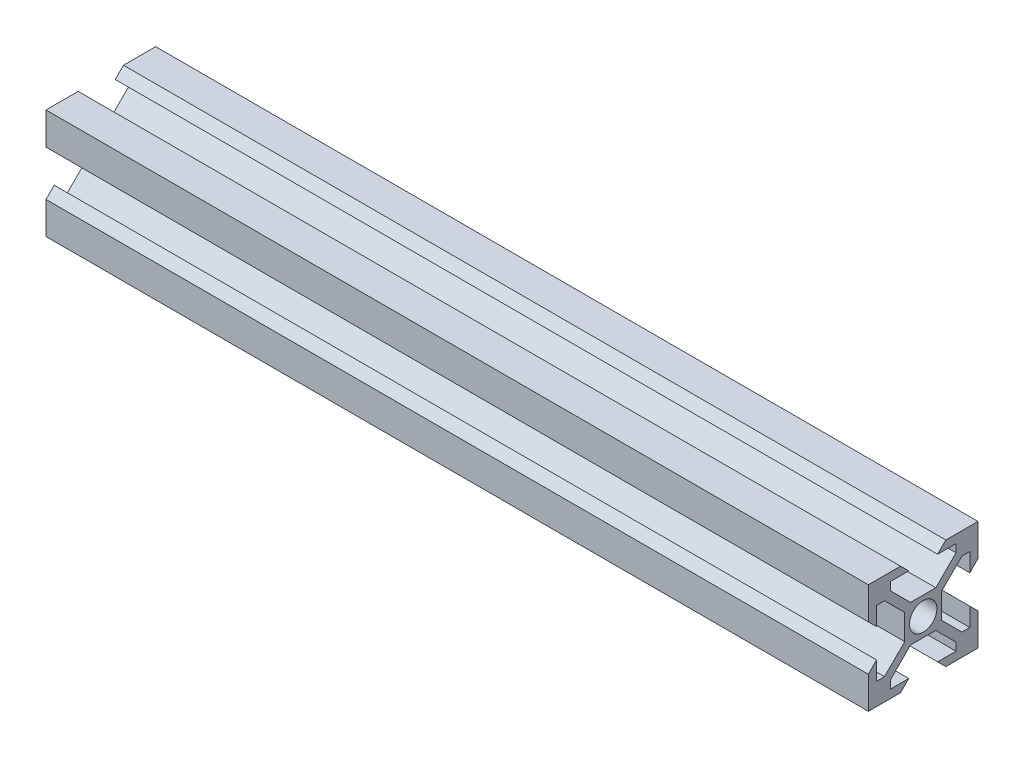
from build123d import *

# Parameters (mm, degrees)
BOSS_EXTRUDE1_DEPTH = 150


with BuildPart() as part:
    # Sketch1 → Boss-Extrude1 (new body)
    with BuildSketch(Plane(origin=(0, 0, 0), x_dir=(0, 0, -1), z_dir=(1, 0, 0))):
        Polygon((8.939339828, -10), (5.995, -7.055660172), (5.995, -8.5), (2.63, -8.5), (4.13, -10), align=None)
        Polygon((8.5, -5.995), (7.055660172, -5.995), (10, -8.939339828), (10, -4.13), (8.5, -2.63), align=None)
        Polygon((7.055660172, -5.995), (3.365, -2.304339828), (3.365, -3.365), (2.304339828, -3.365), (5.995, -7.055660172), (8.939339828, -10), (10, -10), (10, -8.939339828), align=None)
        with BuildLine():
            Line((3.365, -3.365), (3.365, -2.304339828))
            Line((3.365, -2.304339828), (2.216672281, -1.15601211))
            ThreePointArc((2.216672281, -1.15601211), (1.767766953, -1.767766953), (1.15601211, -2.216672281))
            Line((1.15601211, -2.216672281), (2.304339828, -3.365))
            Line((2.304339828, -3.365), (3.365, -3.365))
        make_face()
        with BuildLine():
            Line((3.365, -2.304339828), (3.365, 2.304339828))
            Line((3.365, 2.304339828), (2.216672281, 1.15601211))
            ThreePointArc((2.216672281, 1.15601211), (2.428135159, 0.595113139), (2.5, 0))
            ThreePointArc((2.5, 0), (2.428135159, -0.595113139), (2.216672281, -1.15601211))
            Line((2.216672281, -1.15601211), (3.365, -2.304339828))
        make_face()
        with BuildLine():
            Line((2.216672281, 1.15601211), (3.365, 2.304339828))
            Line((3.365, 2.304339828), (3.365, 3.365))
            Line((3.365, 3.365), (2.304339828, 3.365))
            Line((2.304339828, 3.365), (1.15601211, 2.216672281))
            ThreePointArc((1.15601211, 2.216672281), (1.767766953, 1.767766953), (2.216672281, 1.15601211))
        make_face()
        with BuildLine():
            ThreePointArc((-1.15601211, 2.216672281), (0, 2.5), (1.15601211, 2.216672281))
            Line((1.15601211, 2.216672281), (2.304339828, 3.365))
            Line((2.304339828, 3.365), (-2.304339828, 3.365))
            Line((-2.304339828, 3.365), (-1.15601211, 2.216672281))
        make_face()
        with BuildLine():
            ThreePointArc((-2.216672281, 1.15601211), (-1.767766953, 1.767766953), (-1.15601211, 2.216672281))
            Line((-1.15601211, 2.216672281), (-2.304339828, 3.365))
            Line((-2.304339828, 3.365), (-3.365, 3.365))
            Line((-3.365, 3.365), (-3.365, 2.304339828))
            Line((-3.365, 2.304339828), (-2.216672281, 1.15601211))
        make_face()
        with BuildLine():
            ThreePointArc((-2.216672281, -1.15601211), (-2.5, 0), (-2.216672281, 1.15601211))
            Line((-2.216672281, 1.15601211), (-3.365, 2.304339828))
            Line((-3.365, 2.304339828), (-3.365, -2.304339828))
            Line((-3.365, -2.304339828), (-2.216672281, -1.15601211))
        make_face()
        with BuildLine():
            Line((-2.304339828, -3.365), (-1.15601211, -2.216672281))
            ThreePointArc((-1.15601211, -2.216672281), (-1.767766953, -1.767766953), (-2.216672281, -1.15601211))
            Line((-2.216672281, -1.15601211), (-3.365, -2.304339828))
            Line((-3.365, -2.304339828), (-3.365, -3.365))
            Line((-3.365, -3.365), (-2.304339828, -3.365))
        make_face()
        with BuildLine():
            Line((-2.304339828, -3.365), (2.304339828, -3.365))
            Line((2.304339828, -3.365), (1.15601211, -2.216672281))
            ThreePointArc((1.15601211, -2.216672281), (0, -2.5), (-1.15601211, -2.216672281))
            Line((-1.15601211, -2.216672281), (-2.304339828, -3.365))
        make_face()
        Polygon((10, 4.13), (10, 8.939339828), (7.055660172, 5.995), (8.5, 5.995), (8.5, 2.63), align=None)
        Polygon((7.055660172, 5.995), (10, 8.939339828), (10, 10), (8.939339828, 10), (5.995, 7.055660172), (2.304339828, 3.365), (3.365, 3.365), (3.365, 2.304339828), align=None)
        Polygon((5.995, 7.055660172), (8.939339828, 10), (4.13, 10), (2.63, 8.5), (5.995, 8.5), align=None)
        Polygon((-8.939339828, 10), (-5.995, 7.055660172), (-5.995, 8.5), (-2.63, 8.5), (-4.13, 10), align=None)
        Polygon((-3.365, 3.365), (-2.304339828, 3.365), (-5.995, 7.055660172), (-8.939339828, 10), (-10, 10), (-10, 8.939339828), (-7.055660172, 5.995), (-3.365, 2.304339828), align=None)
        Polygon((-8.5, 5.995), (-7.055660172, 5.995), (-10, 8.939339828), (-10, 4.13), (-8.5, 2.63), align=None)
        Polygon((-10, -8.939339828), (-7.055660172, -5.995), (-8.5, -5.995), (-8.5, -2.63), (-10, -4.13), align=None)
        Polygon((-5.995, -7.055660172), (-2.304339828, -3.365), (-3.365, -3.365), (-3.365, -2.304339828), (-7.055660172, -5.995), (-10, -8.939339828), (-10, -10), (-8.939339828, -10), align=None)
        Polygon((-5.995, -8.5), (-5.995, -7.055660172), (-8.939339828, -10), (-4.13, -10), (-2.63, -8.5), align=None)
    extrude(amount=BOSS_EXTRUDE1_DEPTH)


solid = part.part
